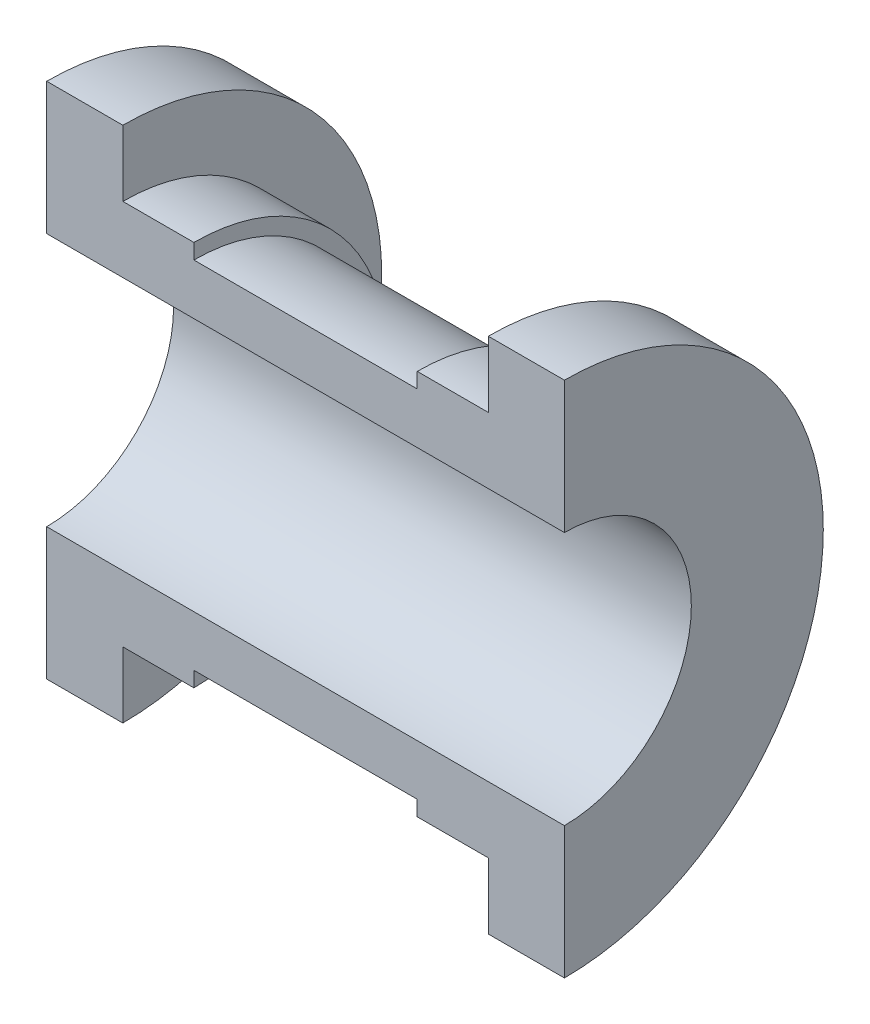
from build123d import *

# Parameters (mm, degrees)
REVOLVE2_ANGLE      = 180
CUT_EXTRUDE1_DEPTH  = 52
SKETCH3_R           = 3
BOSS_EXTRUDE1_DEPTH = 6


with BuildPart() as part:
    # Sketch1 → Revolve2 (revolve)
    with BuildSketch(Plane.XY):
        Polygon((25.5, 0), (25.5, 25.5), (18, 25.5), (18, 19), (11, 19), (11, 17.5), (3, 17.5), (-3, 17.5), (-11, 17.5), (-11, 19), (-18, 19), (-18, 25.5), (-25.5, 25.5), (-25.5, 0), align=None)
    revolve(axis=Axis((25.5, 0, 0), (-1, 0, 0)), revolution_arc=REVOLVE2_ANGLE)

    # Sketch2 → Cut-Extrude1 (cut, through all)
    with BuildSketch(Plane(origin=(25.5, 0, 0), x_dir=(0, 0, -1), z_dir=(1, 0, 0))):
        with BuildLine():
            Line((0, 12.5), (0, -12.5))
            ThreePointArc((0, -12.5), (12.5, 0), (0, 12.5))
        make_face()
    extrude(amount=-CUT_EXTRUDE1_DEPTH, mode=Mode.SUBTRACT)


with BuildPart() as body_2:
    # Sketch3 → Boss-Extrude1 (new body)
    with BuildSketch(Plane.XY.offset(-17.5)):
        Circle(SKETCH3_R)
    extrude(amount=-BOSS_EXTRUDE1_DEPTH)


solid = Compound([part.part, body_2.part])
